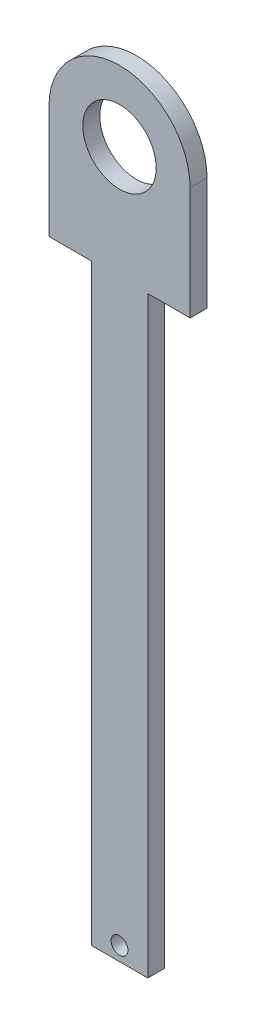
from build123d import *

# Parameters (mm, degrees)
SKETCH1_R           = 13
BOSS_EXTRUDE3_DEPTH = 6
SKETCH3_W           = 20
SKETCH3_H           = 6
BOSS_EXTRUDE4_DEPTH = 200
SKETCH5_W           = 20
SKETCH5_H           = 10
SKETCH5_R           = 3
BOSS_EXTRUDE5_DEPTH = 6


with BuildPart() as part:
    # Sketch1 → Boss-Extrude3 (new body)
    with BuildSketch(Plane.XY):
        with BuildLine():
            Line((77.458052403, 42.618499055), (77.458052403, 2.618499055))
            Line((77.458052403, 2.618499055), (27.458052403, 2.618499055))
            Line((27.458052403, 2.618499055), (27.458052403, 42.618499055))
            ThreePointArc((27.458052403, 42.618499055), (52.458052403, 67.618499055), (77.458052403, 42.618499055))
        make_face()
        with Locations((52.458052403, 42.618499055)):
            Circle(SKETCH1_R, mode=Mode.SUBTRACT)
    extrude(amount=BOSS_EXTRUDE3_DEPTH)

    # Sketch3 → Boss-Extrude4 (add)
    with BuildSketch(Plane.XZ.offset(-2.618499055)):
        with Locations((52.458052403, 3)):
            Rectangle(SKETCH3_W, SKETCH3_H)
    extrude(amount=BOSS_EXTRUDE4_DEPTH)

    # Sketch5 → Boss-Extrude5 (add)
    with BuildSketch(Plane.XY.offset(6)):
        with Locations((52.458052403, -202.381500945)):
            Rectangle(SKETCH5_W, SKETCH5_H)
        with Locations((52.458052403, -202.381500945)):
            Circle(SKETCH5_R, mode=Mode.SUBTRACT)
    extrude(amount=-BOSS_EXTRUDE5_DEPTH)


solid = part.part
